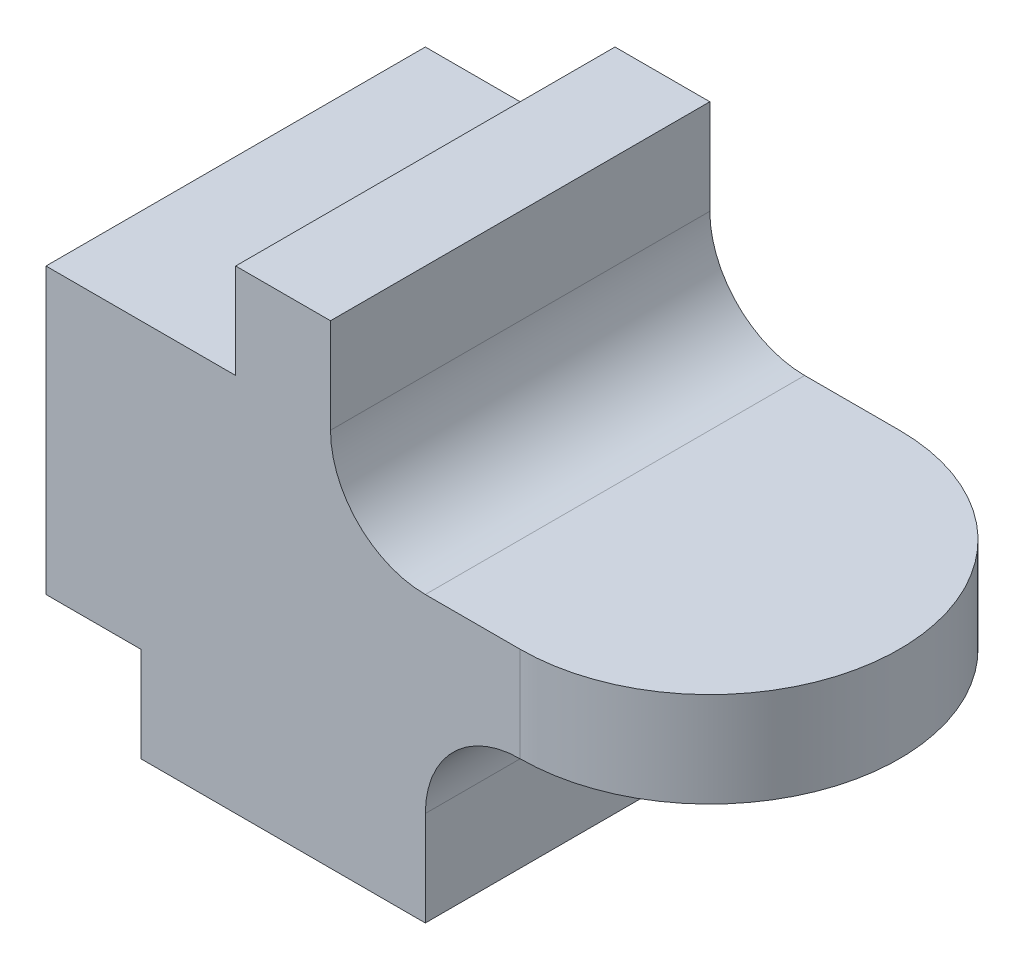
from build123d import *

# Parameters (mm, degrees)
SKETCH_2_W               = 70
SKETCH_2_H               = 40
EXTRUDE_1_DEPTH          = 50
SKETCH_3_W               = 20
SKETCH_3_H               = 10
SKETCH_3_W_2             = 10
CUT_EXTRUDE_1_DEPTH      = 41
CUT_EXTRUDE_3_DEPTH      = 51
CUT_EXTRUDE_3_DEPTH_BACK = 1


with BuildPart() as part:
    # 草圖2 → 填料-伸長1 (new body)
    with BuildSketch(Plane(origin=(0, 0, 0), x_dir=(1, 0, 0), z_dir=(0, 1, 0))):
        Rectangle(SKETCH_2_W, SKETCH_2_H)
    extrude(amount=EXTRUDE_1_DEPTH)

    # 草圖3 → 除料-伸長1 (cut, through all)
    with BuildSketch(Plane.XY.offset(20)):
        with Locations((-25, 45)):
            Rectangle(SKETCH_3_W, SKETCH_3_H)
        with BuildLine():
            Line((5, 30), (35, 30))
            Line((35, 30), (35, 50))
            Line((35, 50), (-5, 50))
            Line((-5, 50), (-5, 40))
            ThreePointArc((-5, 40), (-2.071067812, 32.928932188), (5, 30))
        make_face()
        with BuildLine():
            Line((5, 10), (5, 0))
            Line((5, 0), (35, 0))
            Line((35, 0), (35, 20))
            Line((35, 20), (15, 20))
            ThreePointArc((15, 20), (7.928932188, 17.071067812), (5, 10))
        make_face()
        with Locations((-30, 5)):
            Rectangle(SKETCH_3_W_2, SKETCH_3_H)
    extrude(amount=-CUT_EXTRUDE_1_DEPTH, mode=Mode.SUBTRACT)

    # 草圖4 → 除料-伸長3 (cut, two sides)
    with BuildSketch(Plane(origin=(0, 0, 0), x_dir=(1, 0, 0), z_dir=(0, 1, 0))) as cut_extrude_3_sk:
        with BuildLine():
            Line((35, 20), (15, 20))
            ThreePointArc((15, 20), (29.142135624, 14.142135624), (35, 0))
            Line((35, 0), (35, 20))
        make_face()
        with BuildLine():
            Line((35, -20), (35, 0))
            ThreePointArc((35, 0), (29.142135624, -14.142135624), (15, -20))
            Line((15, -20), (35, -20))
        make_face()
    extrude(amount=CUT_EXTRUDE_3_DEPTH, mode=Mode.SUBTRACT)
    extrude(cut_extrude_3_sk.sketch, amount=-CUT_EXTRUDE_3_DEPTH_BACK, mode=Mode.SUBTRACT)


solid = part.part
